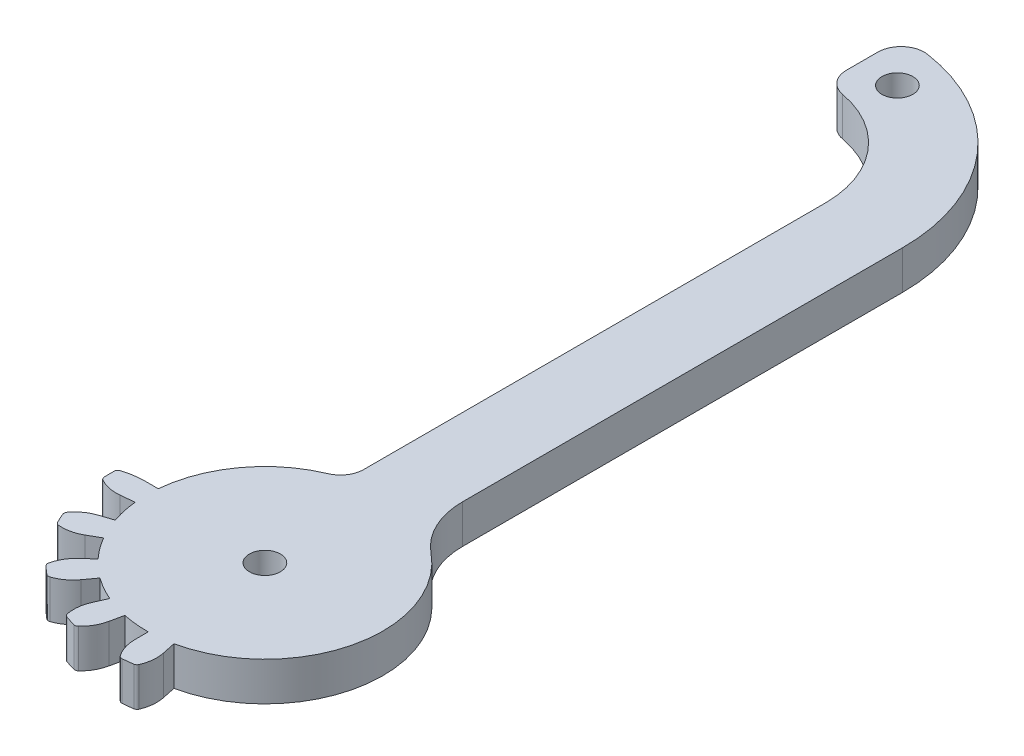
from build123d import *

# Parameters (mm, degrees)
SKETCH1_R           = 2
BOSS_EXTRUDE3_DEPTH = 5
FILLET11_R          = 3
FILLET12_R          = 10
FILLET13_R          = 0.5


with BuildPart() as part:
    # Sketch1 → Boss-Extrude3 (new body)
    with BuildSketch(Plane(origin=(0, 0, 0), x_dir=(1, 0, 0), z_dir=(0, 1, 0))):
        with BuildLine():
            Line((-15.194514721, -20.497190469), (-16.934514721, -20.497190469))
            ThreePointArc((-16.934514721, -20.497190469), (-18.487045158, -20.635059579), (-19.990986096, -21.044352024))
            ThreePointArc((-19.990986096, -21.044352024), (-20.009485456, -22.000591241), (-19.982270663, -22.956622109))
            ThreePointArc((-19.982270663, -22.956622109), (-18.512106636, -23.583403018), (-16.917234096, -23.686447466))
            Line((-16.917234096, -23.686447466), (-15.176510207, -23.503489976))
            ThreePointArc((-15.176510207, -23.503489976), (-14.956675222, -24.936847382), (-14.601778477, -26.342866292))
            ThreePointArc((-14.601778477, -26.342866292), (-14.530483873, -26.571223065), (-14.455618246, -26.798434144))
            Line((-14.455618246, -26.798434144), (-16.120081178, -27.339250934))
            ThreePointArc((-16.120081178, -27.339250934), (-17.530103274, -28.082215528), (-18.614519352, -29.250205455))
            ThreePointArc((-18.614519352, -29.250205455), (-18.242481832, -30.131297816), (-17.828767099, -30.993606221))
            ThreePointArc((-17.828767099, -30.993606221), (-16.230770667, -30.968229498), (-14.731870148, -30.413672187))
            Line((-14.731870148, -30.413672187), (-13.216055258, -29.538516018))
            ThreePointArc((-13.216055258, -29.538516018), (-12.432227031, -30.758538224), (-11.536133313, -31.898650905))
            ThreePointArc((-11.536133313, -31.898650905), (-11.378121368, -32.07826709), (-11.217313126, -32.255384164))
            Line((-11.217313126, -32.255384164), (-12.517905671, -33.426442952))
            ThreePointArc((-12.517905671, -33.426442952), (-13.503834046, -34.678682508), (-14.019433156, -36.186766135))
            ThreePointArc((-14.019433156, -36.186766135), (-13.321187423, -36.84036277), (-12.592507783, -37.459847758))
            ThreePointArc((-12.592507783, -37.459847758), (-11.142987043, -36.786701267), (-9.999232057, -35.670430194))
            Line((-9.999232057, -35.670430194), (-8.970424328, -34.254397795))
            ThreePointArc((-8.970424328, -34.254397795), (-7.758133877, -35.050131881), (-6.47578593, -35.727202496))
            ThreePointArc((-6.47578593, -35.727202496), (-6.258378327, -35.827020809), (-6.03943266, -35.923418714))
            Line((-6.03943266, -35.923418714), (-6.751270551, -37.522232796))
            ThreePointArc((-6.751270551, -37.522232796), (-7.142629255, -39.067223735), (-7.000259644, -40.654639727))
            ThreePointArc((-7.000259644, -40.654639727), (-6.096538725, -40.967727841), (-5.178889508, -41.23727483))
            ThreePointArc((-5.178889508, -41.23727483), (-4.128479759, -40.032751715), (-3.537635932, -38.547780286))
            Line((-3.537635932, -38.547780286), (-3.173725562, -36.835716518))
            ThreePointArc((-3.173725562, -36.835716518), (-1.742588917, -37.069572835), (-0.295716346, -37.166529725))
            ThreePointArc((-0.295716346, -37.166529725), (-0.056504827, -37.169290654), (0.182720579, -37.168301296))
            Line((0.182720579, -37.168301296), (0.182720579, -38.918421193))
            ThreePointArc((0.182720579, -38.918421193), (0.453601009, -40.489020569), (1.229322337, -41.881290308))
            ThreePointArc((1.229322337, -41.881290308), (2.182256886, -41.799734123), (3.130205798, -41.672735992))
            ThreePointArc((3.130205798, -41.672735992), (3.59987917, -40.145109238), (3.535649575, -38.548202499))
            Line((3.535649575, -38.548202499), (3.171739177, -36.836138737))
            ThreePointArc((3.171739177, -36.836138737), (15.191099578, -23.357875025), (5.935485279, -7.851030694))
            Line((5.935485279, -7.851030694), (5.935485279, 54.590604732))
            ThreePointArc((5.935485279, 54.590604732), (-0.947505363, 71.20761409), (-17.564514721, 78.090604732))
            Line((-17.564514721, 78.090604732), (-17.564514721, 68.090604732))
            ThreePointArc((-17.564514721, 68.090604732), (-8.018573175, 64.136546278), (-4.064514721, 54.590604732))
            Line((-4.064514721, 54.590604732), (-4.064514721, -7.200645488))
            ThreePointArc((-4.064514721, -7.200645488), (-11.701584545, -12.114472137), (-15.194514721, -20.497190469))
        make_face()
        with Locations((0, -21.909395268)):
            Circle(SKETCH1_R, mode=Mode.SUBTRACT)
        with Locations((-12.564514721, 72.402117863)):
            Circle(SKETCH1_R, mode=Mode.SUBTRACT)
    extrude(amount=BOSS_EXTRUDE3_DEPTH)

    # Fillet11
    fillet11_edges = [part.edges().sort_by_distance(p)[0] for p in [
        (-4.064514721, 2.5, 7.200645488),
        (-17.564514721, 2.5, -68.090604732),
        (-17.564514721, 2.5, -78.090604732),
    ]]
    fillet(fillet11_edges, radius=FILLET11_R)

    # Fillet12
    fillet12_edges = [part.edges().sort_by_distance(p)[0] for p in [
        (5.935485279, 2.5, 7.851030694),
    ]]
    fillet(fillet12_edges, radius=FILLET12_R)

    # Fillet13
    fillet13_edges = [part.edges().sort_by_distance(p)[0] for p in [
        (3.130205798, 2.5, 41.672735992),
        (1.229322337, 2.5, 41.881290308),
        (-5.178889508, 2.5, 41.23727483),
        (-7.000259644, 2.5, 40.654639727),
        (-12.592507783, 2.5, 37.459847758),
        (-14.019433156, 2.5, 36.186766135),
        (-17.828767099, 2.5, 30.993606221),
        (-18.614519352, 2.5, 29.250205455),
        (-19.982270663, 2.5, 22.956622109),
        (-19.990986096, 2.5, 21.044352024),
    ]]
    fillet(fillet13_edges, radius=FILLET13_R)


solid = part.part
